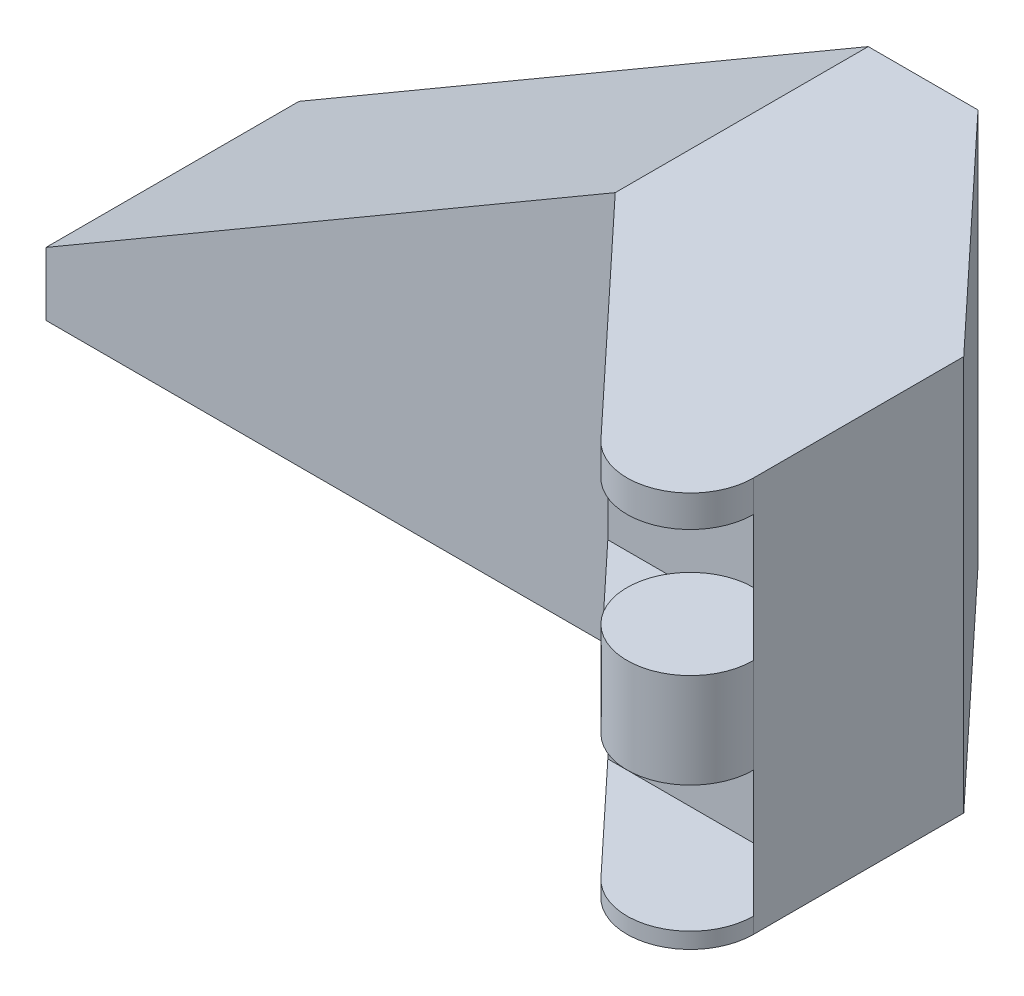
from build123d import *

# Parameters (mm, degrees)
BOSS_EXTRUDE1_DEPTH = 39.6875
CUT_EXTRUDE1_DEPTH  = 12.7
CUT_EXTRUDE2_DEPTH  = 12.7
CUT_EXTRUDE3_DEPTH  = 3.175
CUT_EXTRUDE4_START  = -9.525
CUT_EXTRUDE4_DEPTH  = 3.175
CUT_EXTRUDE5_DEPTH  = 50.609375


with BuildPart() as part:
    # Sketch1 → Boss-Extrude1 (new body)
    with BuildSketch(Plane(origin=(0, 0, 0), x_dir=(1, 0, 0), z_dir=(0, 1, 0))):
        with BuildLine():
            Line((-12.7, 0), (-69.85, 0))
            Line((-69.85, 0), (-69.85, 25.4))
            Line((-69.85, 25.4), (-1.678775343, 25.4))
            Line((-1.678775343, 25.4), (19.05, 3.238927777))
            Line((19.05, 3.238927777), (19.05, -17.859375))
            ThreePointArc((19.05, -17.859375), (15.031784758, -23.765751202), (8.062510285, -22.19713815))
            Line((8.062510285, -22.19713815), (-12.7, 0))
        make_face()
    extrude(amount=BOSS_EXTRUDE1_DEPTH)

    # Sketch2 → Cut-Extrude1 (cut)
    with BuildSketch(Plane(origin=(0, 36.5125, 0), x_dir=(1, 0, 0), z_dir=(0, 1, 0))):
        with BuildLine():
            Line((12.7, -11.509375), (-1.934489816, -11.509375))
            Line((-1.934489816, -11.509375), (8.062510285, -22.19713815))
            ThreePointArc((8.062510285, -22.19713815), (18.525259479, -20.386992851), (12.7, -11.509375))
        make_face()
    extrude(amount=-CUT_EXTRUDE1_DEPTH, mode=Mode.SUBTRACT)

    # Sketch3 → Cut-Extrude2 (cut)
    with BuildSketch(Plane(origin=(0, 14.2875, 0), x_dir=(1, 0, 0), z_dir=(0, 1, 0))):
        with BuildLine():
            Line((12.7, -11.509375), (-1.934489816, -11.509375))
            Line((-1.934489816, -11.509375), (8.062510285, -22.19713815))
            ThreePointArc((8.062510285, -22.19713815), (18.525259479, -20.386992851), (12.7, -11.509375))
        make_face()
    extrude(amount=-CUT_EXTRUDE2_DEPTH, mode=Mode.SUBTRACT)

    # Sketch4 → Cut-Extrude3 (cut)
    with BuildSketch(Plane(origin=(0, 23.8125, 0), x_dir=(1, 0, 0), z_dir=(0, 1, 0))):
        with BuildLine():
            Line((12.7, -11.509375), (-1.934489816, -11.509375))
            Line((-1.934489816, -11.509375), (8.062510285, -22.19713815))
            ThreePointArc((8.062510285, -22.19713815), (6.874740521, -15.331757149), (12.7, -11.509375))
        make_face()
    extrude(amount=-CUT_EXTRUDE3_DEPTH, mode=Mode.SUBTRACT)

    # Sketch4_2 → Cut-Extrude4 (cut)
    with BuildSketch(Plane(origin=(0, 23.8125, 0), x_dir=(1, 0, 0), z_dir=(0, 1, 0)).offset(CUT_EXTRUDE4_START)):
        with BuildLine():
            Line((12.7, -11.509375), (-1.934489816, -11.509375))
            Line((-1.934489816, -11.509375), (8.062510285, -22.19713815))
            ThreePointArc((8.062510285, -22.19713815), (6.874740521, -15.331757149), (12.7, -11.509375))
        make_face()
    extrude(amount=CUT_EXTRUDE4_DEPTH, mode=Mode.SUBTRACT)

    # Sketch5 → Cut-Extrude5 (cut, through all)
    with BuildSketch(Plane(origin=(0, 0, -25.4), x_dir=(-1, 0, 0), z_dir=(0, 0, -1))):
        Polygon((69.85, 6.35), (12.7, 39.6875), (69.85, 39.6875), align=None)
    extrude(amount=-CUT_EXTRUDE5_DEPTH, mode=Mode.SUBTRACT)


solid = part.part
